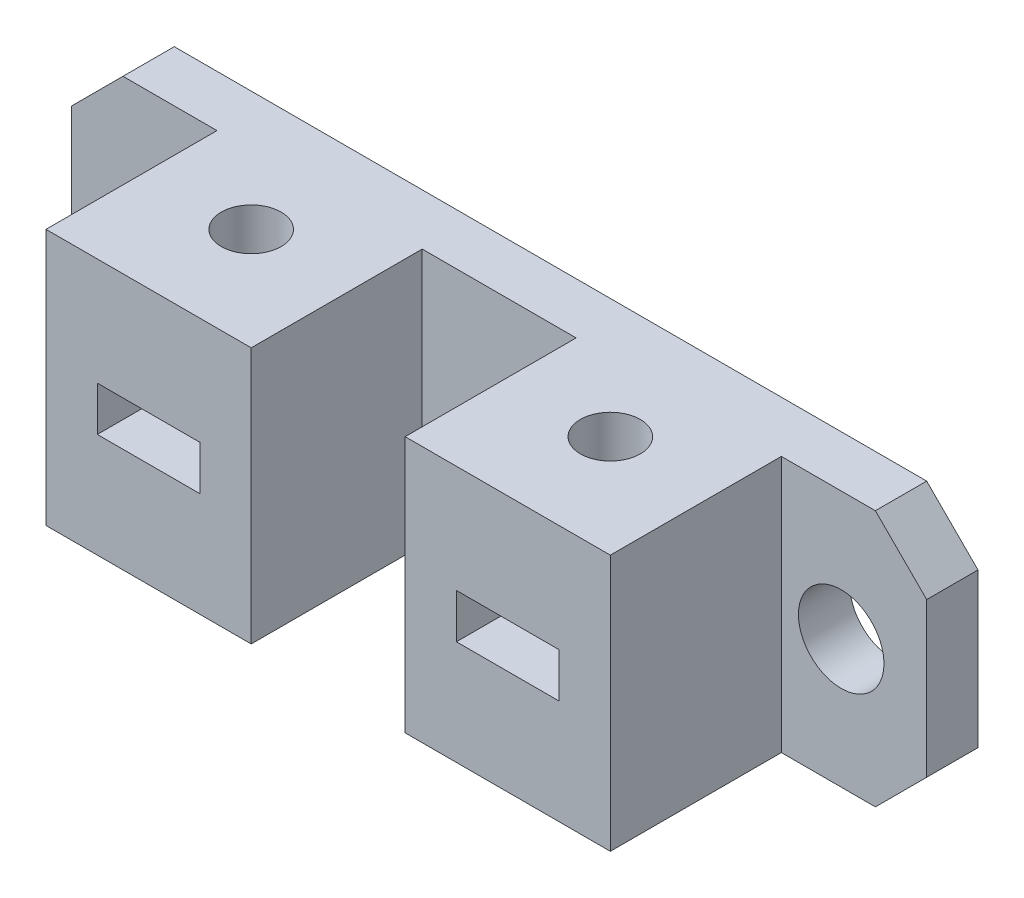
from build123d import *

# Parameters (mm, degrees)
SKETCH1_W           = 50
SKETCH1_H           = 15
BOSS_EXTRUDE1_DEPTH = 3
SKETCH2_R           = 2.5
CUT_EXTRUDE1_DEPTH  = 4
SKETCH3_W           = 12
SKETCH3_H           = 15
SKETCH3_W_2         = 6
SKETCH3_H_2         = 2.6
BOSS_EXTRUDE2_DEPTH = 10
SKETCH4_R           = 1.75
CUT_EXTRUDE2_DEPTH  = 16
CHAMFER1_SIZE       = 3


with BuildPart() as part:
    # Sketch1 → Boss-Extrude1 (new body)
    with BuildSketch(Plane.XY):
        with Locations((25, 7.5)):
            Rectangle(SKETCH1_W, SKETCH1_H)
    extrude(amount=BOSS_EXTRUDE1_DEPTH)

    # Sketch2 → Cut-Extrude1 (cut, through all)
    with BuildSketch(Plane.XY.offset(3)):
        with Locations((5, 7.5)):
            Circle(SKETCH2_R)
        with Locations((45, 7.5)):
            Circle(SKETCH2_R)
    extrude(amount=-CUT_EXTRUDE1_DEPTH, mode=Mode.SUBTRACT)

    # Sketch3 → Boss-Extrude2 (add)
    with BuildSketch(Plane.XY.offset(3)):
        with Locations((14.5, 7.5)):
            Rectangle(SKETCH3_W, SKETCH3_H)
        with Locations((14.5, 7.412594685)):
            Rectangle(SKETCH3_W_2, SKETCH3_H_2, mode=Mode.SUBTRACT)
        with Locations((35.5, 7.5)):
            Rectangle(SKETCH3_W, SKETCH3_H)
        with Locations((35.5, 7.412594685)):
            Rectangle(SKETCH3_W_2, SKETCH3_H_2, mode=Mode.SUBTRACT)
    extrude(amount=BOSS_EXTRUDE2_DEPTH)

    # Sketch4 → Cut-Extrude2 (cut, through all)
    with BuildSketch(Plane(origin=(0, 15, 0), x_dir=(1, 0, 0), z_dir=(0, 1, 0))):
        with Locations((35.5, -7)):
            Circle(SKETCH4_R)
        with Locations((14.5, -7)):
            Circle(SKETCH4_R)
    extrude(amount=-CUT_EXTRUDE2_DEPTH, mode=Mode.SUBTRACT)

    # Chamfer1
    chamfer1_edges = [part.edges().sort_by_distance(p)[0] for p in [
        (50, 15, 1.5),
        (50, 0, 1.5),
        (0, 0, 1.5),
        (0, 15, 1.5),
    ]]
    chamfer(chamfer1_edges, length=CHAMFER1_SIZE)


solid = part.part
